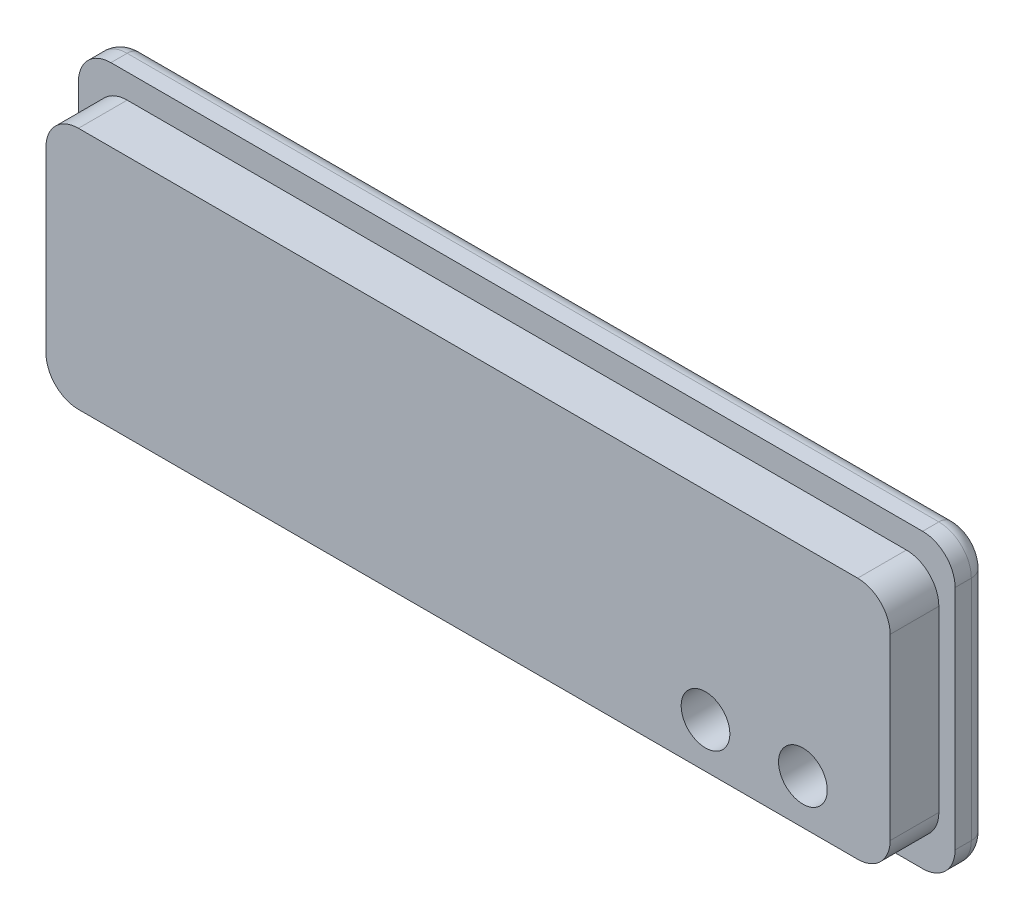
from build123d import *

# Parameters (mm, degrees)
BOSS_EXTRUDE1_DEPTH = 2
BOSS_EXTRUDE2_DEPTH = 3
SKETCH4_R           = 1.5
CUT_EXTRUDE1_DEPTH  = 7
FILLET1_R           = 1


with BuildPart() as part:
    # Sketch1 → Boss-Extrude1 (new body)
    with BuildSketch(Plane.XY):
        with BuildLine():
            Line((25, 9), (-25, 9))
            ThreePointArc((-25, 9), (-26.414213562, 8.414213562), (-27, 7))
            Line((-27, 7), (-27, -7))
            ThreePointArc((-27, -7), (-26.414213562, -8.414213562), (-25, -9))
            Line((-25, -9), (25, -9))
            ThreePointArc((25, -9), (26.414213562, -8.414213562), (27, -7))
            Line((27, -7), (27, 7))
            ThreePointArc((27, 7), (26.414213562, 8.414213562), (25, 9))
        make_face()
    extrude(amount=BOSS_EXTRUDE1_DEPTH)

    # Sketch2 → Boss-Extrude2 (add)
    with BuildSketch(Plane.XY.offset(2)):
        with BuildLine():
            Line((24, -7.5), (-24, -7.5))
            ThreePointArc((-24, -7.5), (-25.414213562, -6.914213562), (-26, -5.5))
            Line((-26, -5.5), (-26, 5.5))
            ThreePointArc((-26, 5.5), (-25.414213562, 6.914213562), (-24, 7.5))
            Line((-24, 7.5), (24, 7.5))
            ThreePointArc((24, 7.5), (25.414213562, 6.914213562), (26, 5.5))
            Line((26, 5.5), (26, -5.5))
            ThreePointArc((26, -5.5), (25.414213562, -6.914213562), (24, -7.5))
        make_face()
    extrude(amount=BOSS_EXTRUDE2_DEPTH)

    # Sketch4 → Cut-Extrude1 (cut)
    with BuildSketch(Plane(origin=(0, 0, 0), x_dir=(-1, 0, 0), z_dir=(0, 0, -1))):
        with Locations((-20.625599185, -4.74532022)):
            Circle(SKETCH4_R)
        with Locations((-14.625599185, -4.74532022)):
            Circle(SKETCH4_R)
    extrude(amount=-CUT_EXTRUDE1_DEPTH, mode=Mode.SUBTRACT)

    # Fillet1
    fillet1_edges = [part.edges().sort_by_distance(p)[0] for p in [
        (0, -9, 0),
        (-26.414213562, -8.414213562, 0),
        (-27, 0, 0),
        (-26.414213562, 8.414213562, 0),
        (0, 9, 0),
        (26.414213562, 8.414213562, 0),
        (27, 0, 0),
        (26.414213562, -8.414213562, 0),
    ]]
    fillet(fillet1_edges, radius=FILLET1_R)


solid = part.part
